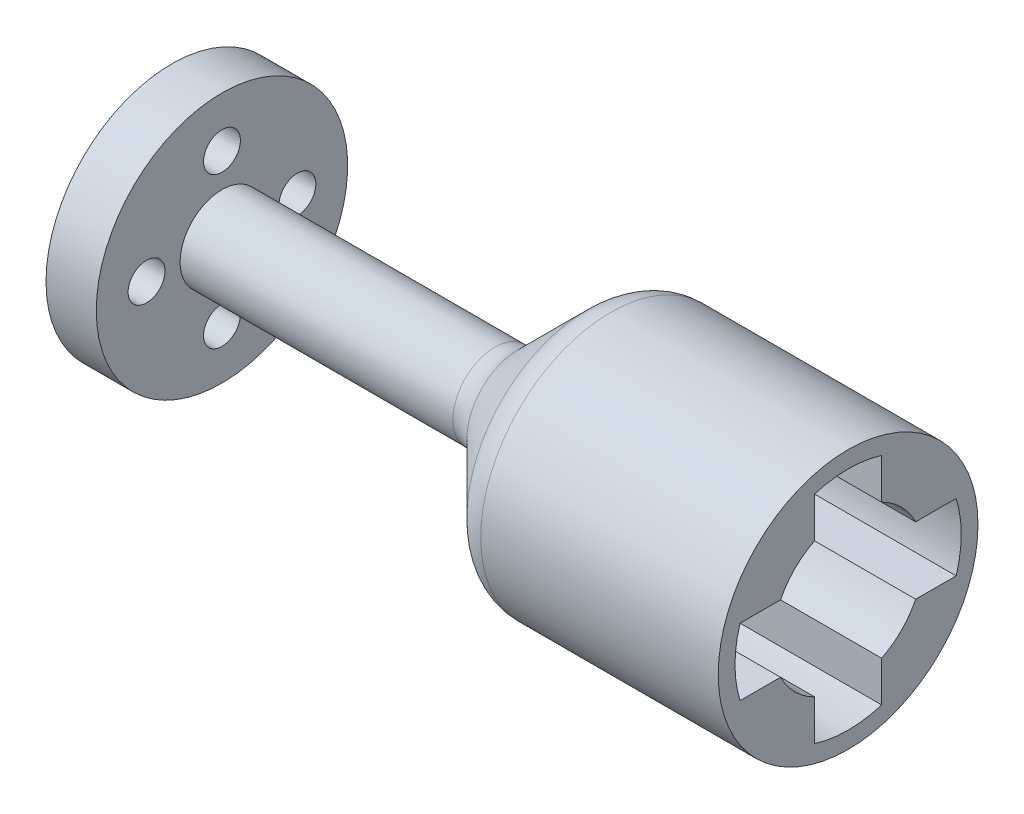
from build123d import *

# Parameters (mm, degrees)
CUT_EXTRUDE1_DEPTH = 13
CIRPATTERN1_COUNT  = 4
SKETCH3_R          = 4.5
CUT_EXTRUDE2_DEPTH = 14
CUT_EXTRUDE3_REACH = 42.36
SKETCH4_R          = 1.1
FILLET1_R          = 2


with BuildPart() as part:
    # Sketch1 → Revolve1 (revolve)
    with BuildSketch(Plane.XY):
        Polygon((-4, 7.75), (11, 7.75), (11, 0), (-29.35982328, 0), (-29.35982328, 7.5), (-26.35982328, 7.5), (-26.35982328, 2.5), (-9.25, 2.5), align=None)
    revolve(axis=Axis((0, 0, 0), (1, 0, 0)))

    # Sketch2 → Cut-Extrude1 (cut)
    with BuildSketch(Plane(origin=(11, 0, 0), x_dir=(0, 0, -1), z_dir=(1, 0, 0))):
        with BuildLine():
            Line((-2, 0), (2, 0))
            Line((2, 0), (2, 6.446898479))
            ThreePointArc((2, 6.446898479), (0, 6.75), (-2, 6.446898479))
            Line((-2, 6.446898479), (-2, 0))
        make_face()
    cut_extrude1 = extrude(amount=-CUT_EXTRUDE1_DEPTH, mode=Mode.SUBTRACT)

    # CirPattern1: Cut-Extrude1 ×4 about axis
    cirpattern1_axis = Axis((0, 0, 0), (1, 0, 0))
    for i in range(1, CIRPATTERN1_COUNT):
        add(cut_extrude1.rotate(cirpattern1_axis, i * 360 / CIRPATTERN1_COUNT), mode=Mode.SUBTRACT)

    # Sketch3 → Cut-Extrude2 (cut, through all)
    with BuildSketch(Plane(origin=(-2, 0, 0), x_dir=(0, 0, -1), z_dir=(1, 0, 0))):
        Circle(SKETCH3_R)
    extrude(amount=CUT_EXTRUDE2_DEPTH, mode=Mode.SUBTRACT)

    # Sketch4 → Cut-Extrude3 (cut, up to next)
    with BuildSketch(Plane.ZY.offset(29.35982328), mode=Mode.PRIVATE) as cut_extrude3_sk1:
        with Locations((0, 4.5)):
            Circle(SKETCH4_R)
    cut_extrude3_tool1 = extrude(cut_extrude3_sk1.sketch, amount=-CUT_EXTRUDE3_REACH, mode=Mode.PRIVATE) & part.part
    add(cut_extrude3_tool1.solids().sort_by_distance((-29.359823, 4.5, 0))[0], mode=Mode.SUBTRACT)
    # Sketch4 → Cut-Extrude3 (cut, up to next)
    with BuildSketch(Plane.ZY.offset(29.35982328), mode=Mode.PRIVATE) as cut_extrude3_sk2:
        with Locations((4.5, 0)):
            Circle(SKETCH4_R)
    cut_extrude3_tool2 = extrude(cut_extrude3_sk2.sketch, amount=-CUT_EXTRUDE3_REACH, mode=Mode.PRIVATE) & part.part
    add(cut_extrude3_tool2.solids().sort_by_distance((-29.359823, 0, 4.5))[0], mode=Mode.SUBTRACT)
    # Sketch4 → Cut-Extrude3 (cut, up to next)
    with BuildSketch(Plane.ZY.offset(29.35982328), mode=Mode.PRIVATE) as cut_extrude3_sk3:
        with Locations((0, -4.5)):
            Circle(SKETCH4_R)
    cut_extrude3_tool3 = extrude(cut_extrude3_sk3.sketch, amount=-CUT_EXTRUDE3_REACH, mode=Mode.PRIVATE) & part.part
    add(cut_extrude3_tool3.solids().sort_by_distance((-29.359823, -4.5, 0))[0], mode=Mode.SUBTRACT)
    # Sketch4 → Cut-Extrude3 (cut, up to next)
    with BuildSketch(Plane.ZY.offset(29.35982328), mode=Mode.PRIVATE) as cut_extrude3_sk4:
        with Locations((-4.5, 0)):
            Circle(SKETCH4_R)
    cut_extrude3_tool4 = extrude(cut_extrude3_sk4.sketch, amount=-CUT_EXTRUDE3_REACH, mode=Mode.PRIVATE) & part.part
    add(cut_extrude3_tool4.solids().sort_by_distance((-29.359823, 0, -4.5))[0], mode=Mode.SUBTRACT)

    # Fillet1
    fillet1_edges = [part.edges().sort_by_distance(p)[0] for p in [
        (-9.25, -2.5, 0),
        (-4, -7.75, 0),
    ]]
    fillet(fillet1_edges, radius=FILLET1_R)

    # Sketch5 → Cut-Revolve1 (revolve, cut)
    with BuildSketch(Plane.XY):
        Polygon((-29.35982328, 0), (-24.25982328, 0), (-25.35982328, 1.1), (-29.35982328, 1.1), align=None)
    revolve(axis=Axis((-29.35982328, 0, 0), (-1, 0, 0)), mode=Mode.SUBTRACT)


solid = part.part
